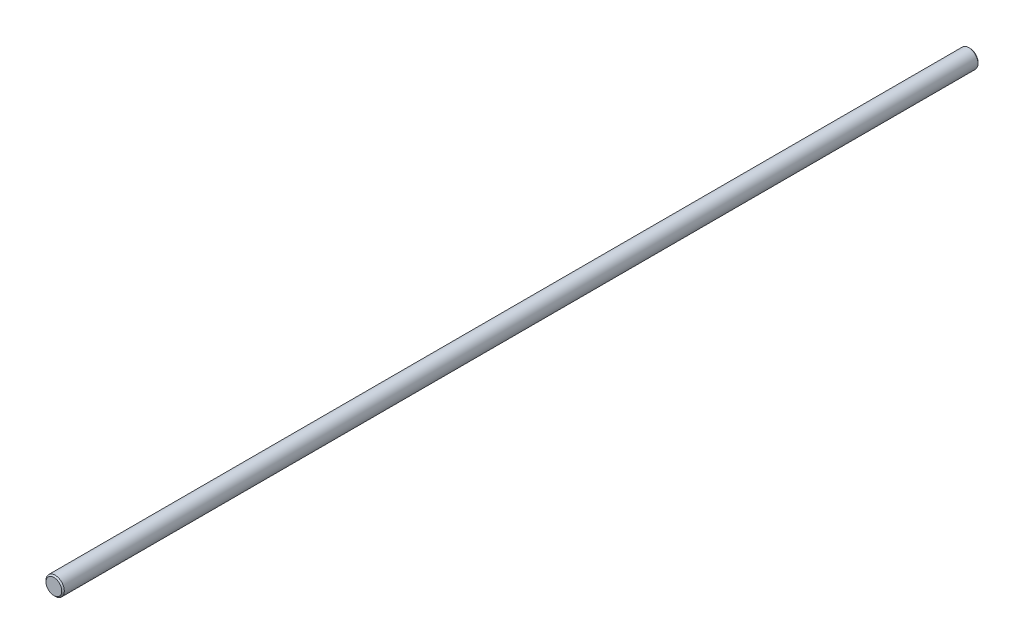
from build123d import *

# Parameters (mm, degrees)
SKETCH3_R                = 3
BOSS_EXTRUDE1_DEPTH      = 150
BOSS_EXTRUDE1_DEPTH_BACK = 150
CHAMFER1_SIZE            = 0.42


with BuildPart() as part:
    # Sketch3 → Boss-Extrude1 (new body, two sides)
    with BuildSketch(Plane.XY) as boss_extrude1_sk:
        Circle(SKETCH3_R)
    extrude(amount=BOSS_EXTRUDE1_DEPTH)
    extrude(boss_extrude1_sk.sketch, amount=-BOSS_EXTRUDE1_DEPTH_BACK)

    # Chamfer1
    chamfer1_edges = [part.edges().sort_by_distance(p)[0] for p in [
        (-3, 0, -150),
        (-3, 0, 150),
    ]]
    chamfer(chamfer1_edges, length=CHAMFER1_SIZE)


solid = part.part
